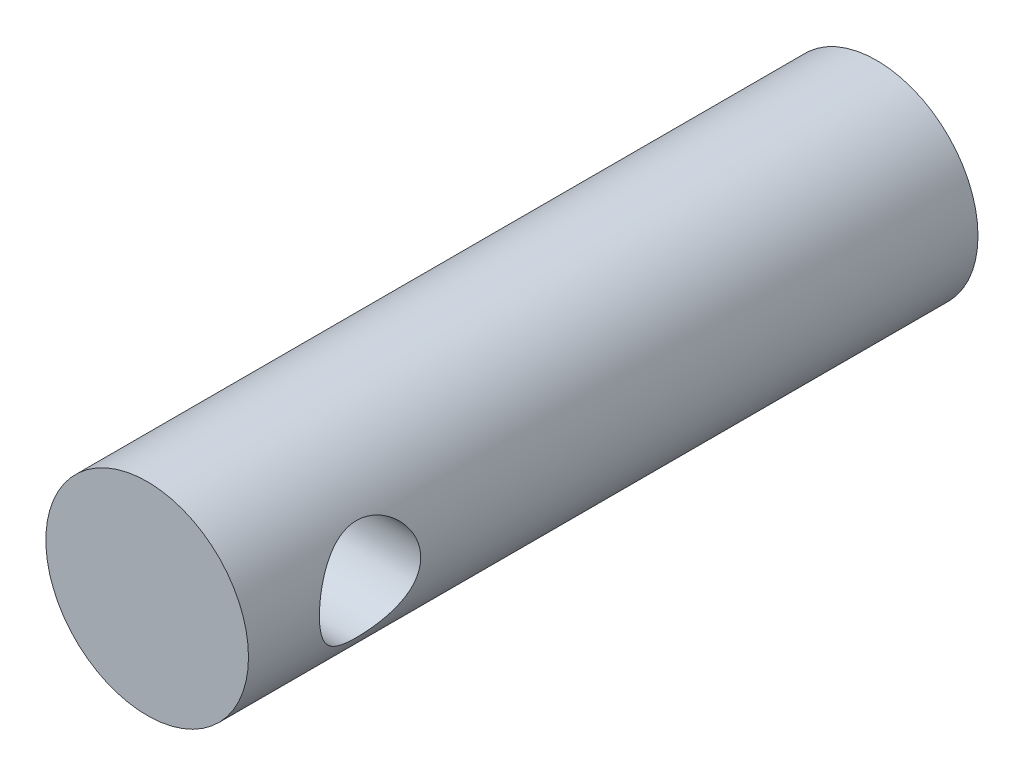
from build123d import *

# Parameters (mm, degrees)
SKETCH1_R               = 2.5
BOSS_EXTRUDE1_DEPTH     = 18
SKETCH2_R               = 1.25
CUT_EXTRUDE2_DEPTH      = 3.5
CUT_EXTRUDE2_DEPTH_BACK = 3.5


with BuildPart() as part:
    # Sketch1 → Boss-Extrude1 (new body)
    with BuildSketch(Plane.XY):
        Circle(SKETCH1_R)
    extrude(amount=BOSS_EXTRUDE1_DEPTH)

    # Sketch2 → Cut-Extrude2 (cut, two sides)
    with BuildSketch(Plane(origin=(0, 0, 0), x_dir=(0, 0, -1), z_dir=(1, 0, 0))) as cut_extrude2_sk:
        with Locations((-15, 0)):
            Circle(SKETCH2_R)
    extrude(amount=CUT_EXTRUDE2_DEPTH, mode=Mode.SUBTRACT)
    extrude(cut_extrude2_sk.sketch, amount=-CUT_EXTRUDE2_DEPTH_BACK, mode=Mode.SUBTRACT)


solid = part.part
